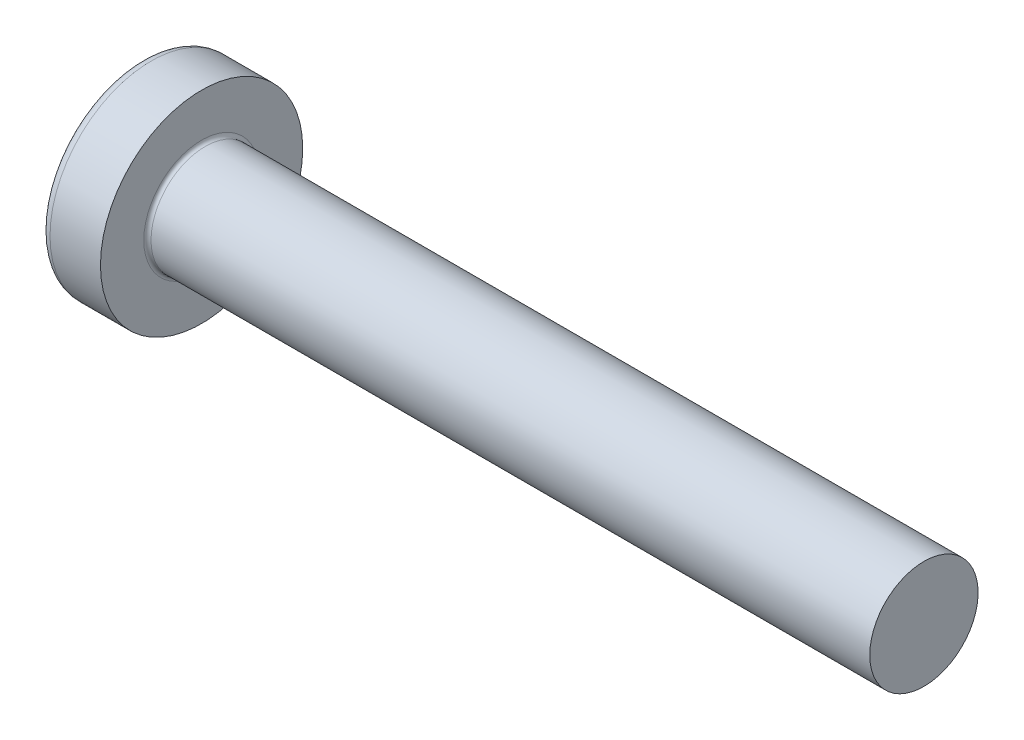
from build123d import *

# Parameters (mm, degrees)
FILLET1_R    = 0.1
SKETCH3_W    = 0.74
SKETCH3_H    = 2.8
SKETCH4_W    = 0.74
SKETCH4_H    = 1.054964432
RECPAT_COUNT = 2
RECPAT_ANGLE = 90


with BuildPart() as part:
    # BodySke → Base-Revolve (revolve)
    with BuildSketch(Plane.XY):
        with BuildLine():
            Line((2.4, 1.5), (2.4, 2.8))
            Line((2.4, 2.8), (1.003501533, 2.8))
            ThreePointArc((1.003501533, 2.8), (0.873295971, 2.76653015), (0.775371599, 2.674418605))
            ThreePointArc((0.775371599, 2.674418605), (0.197753546, 1.392274756), (0, 0))
            Line((0, 0), (22.4, 0))
            Line((22.4, 0), (22.4, 1.5))
            Line((22.4, 1.5), (2.4, 1.5))
        make_face()
    revolve(axis=Axis((-25.4, 0, 0), (1, 0, 0)))

    # Fillet1
    fillet1_edges = [part.edges().sort_by_distance(p)[0] for p in [
        (2.4, -1.5, 0),
    ]]
    fillet(fillet1_edges, radius=FILLET1_R)

    # Sketch3 → Recess section 0
    with BuildSketch(Plane(origin=(0, 0, 0), x_dir=(0, 0, -1), z_dir=(1, 0, 0))):
        Rectangle(SKETCH3_W, SKETCH3_H)
    # Sketch4 → Recess section 1
    with BuildSketch(Plane(origin=(1.75, 0, 0), x_dir=(0, 0, -1), z_dir=(1, 0, 0))):
        Rectangle(SKETCH4_W, SKETCH4_H)
    recess = loft(mode=Mode.SUBTRACT)

    # RecPat: Recess ×2 about axis
    recpat_axis = Axis((0, 0, 0), (1, 0, 0))
    for i in range(1, RECPAT_COUNT):
        add(recess.rotate(recpat_axis, i * RECPAT_ANGLE / (RECPAT_COUNT - 1)), mode=Mode.SUBTRACT)

    # RecCorSke → RecessCore (revolve, cut)
    with BuildSketch(Plane.XY):
        Polygon((0, 0), (0, 0.678371921), (1.75, 0.556), (1.930655351, 0), align=None)
    revolve(axis=Axis((-3.175, 0, 0), (1, 0, 0)), mode=Mode.SUBTRACT)


solid = part.part
